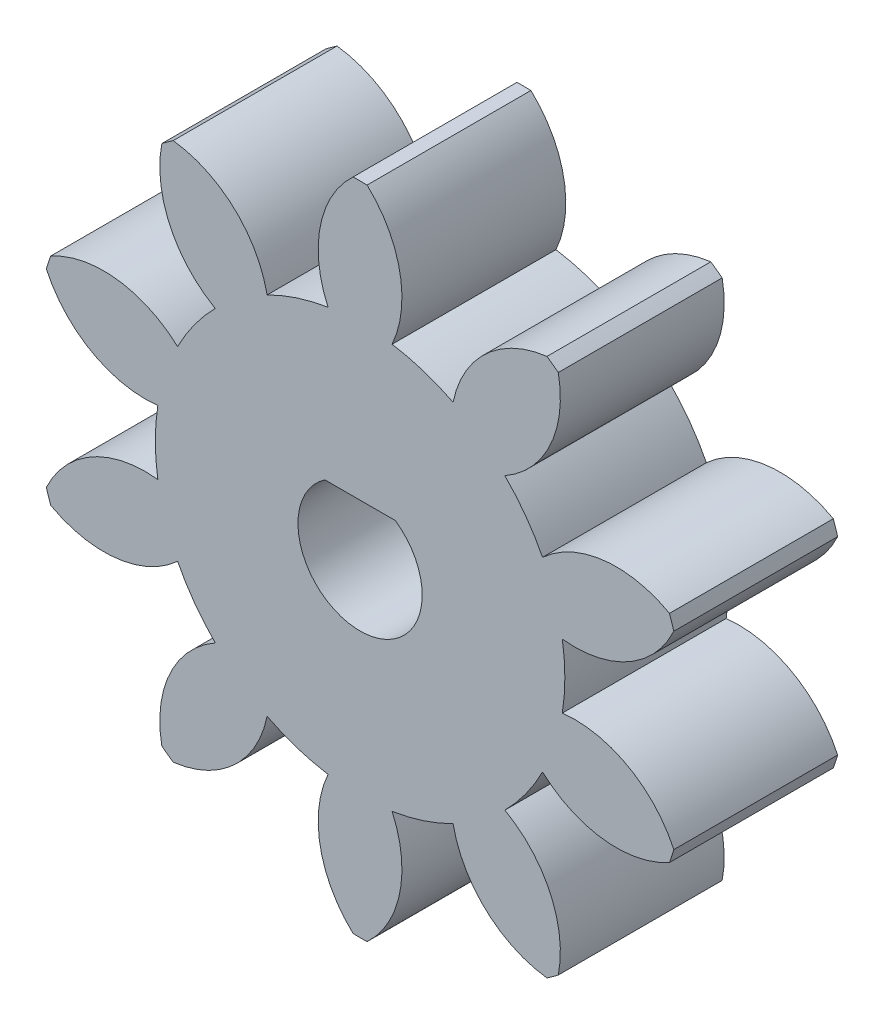
from build123d import *

# Parameters (mm, degrees)
SKETCH4_R           = 2
BOSS_EXTRUDE3_DEPTH = 6
SKETCH6_R           = 3.276903459
BOSS_EXTRUDE4_DEPTH = 6
CUT_EXTRUDE1_DEPTH  = 10


with BuildPart() as part:
    # Sketch4 → Boss-Extrude3 (new body)
    with BuildSketch(Plane.XY):
        with BuildLine():
            ThreePointArc((11.330682707, 3.9516616), (8.917819898, 4.428819506), (6.681915604, 3.403968986))
            ThreePointArc((6.681915604, 3.403968986), (6.066818441, 4.407801607), (5.302192362, 5.302995112))
            ThreePointArc((5.302192362, 5.302995112), (6.967815552, 7.112770233), (7.259627029, 9.554989032))
            ThreePointArc((7.259627029, 9.554989032), (7.053423028, 9.708203932), (6.843986457, 9.856969584))
            ThreePointArc((6.843986457, 9.856969584), (4.61147306, 8.824753264), (3.40498051, 6.681400208))
            ThreePointArc((3.40498051, 6.681400208), (2.317318441, 7.131972816), (1.172541409, 7.406763642))
            ThreePointArc((1.172541409, 7.406763642), (1.456299749, 9.849931218), (0.256880001, 11.997250213))
            ThreePointArc((0.256880001, 11.997250213), (0, 12), (-0.256880001, 11.997250213))
            ThreePointArc((-0.256880001, 11.997250213), (-1.456299749, 9.849931218), (-1.172541409, 7.406763642))
            ThreePointArc((-1.172541409, 7.406763642), (-2.317318441, 7.131972816), (-3.404980509, 6.681400207))
            ThreePointArc((-3.404980509, 6.681400207), (-4.61147306, 8.824753264), (-6.843986457, 9.856969584))
            ThreePointArc((-6.843986457, 9.856969584), (-7.053423028, 9.708203933), (-7.259627029, 9.554989032))
            ThreePointArc((-7.259627029, 9.554989032), (-6.967815552, 7.112770233), (-5.302192362, 5.302995112))
            ThreePointArc((-5.302192362, 5.302995112), (-6.066818441, 4.407801607), (-6.681915604, 3.403968986))
            ThreePointArc((-6.681915604, 3.403968986), (-8.917819898, 4.428819506), (-11.330682707, 3.9516616))
            ThreePointArc((-11.330682707, 3.9516616), (-11.412678196, 3.708203933), (-11.489443278, 3.463046803))
            ThreePointArc((-11.489443278, 3.463046803), (-9.817862641, 1.658772773), (-7.406586048, 1.173662691))
            ThreePointArc((-7.406586048, 1.173662691), (-7.499, 0), (-7.406586048, -1.173662691))
            ThreePointArc((-7.406586048, -1.173662691), (-9.817862641, -1.658772773), (-11.489443278, -3.463046803))
            ThreePointArc((-11.489443278, -3.463046803), (-11.412678196, -3.708203933), (-11.330682707, -3.9516616))
            ThreePointArc((-11.330682707, -3.9516616), (-8.917819898, -4.428819506), (-6.681915604, -3.403968986))
            ThreePointArc((-6.681915604, -3.403968986), (-6.066818441, -4.407801607), (-5.302192362, -5.302995112))
            ThreePointArc((-5.302192362, -5.302995112), (-6.967815552, -7.112770233), (-7.259627029, -9.554989032))
            ThreePointArc((-7.259627029, -9.554989032), (-7.053423028, -9.708203932), (-6.843986457, -9.856969584))
            ThreePointArc((-6.843986457, -9.856969584), (-4.61147306, -8.824753264), (-3.404980509, -6.681400207))
            ThreePointArc((-3.404980509, -6.681400207), (-2.317318441, -7.131972816), (-1.172541409, -7.406763642))
            ThreePointArc((-1.172541409, -7.406763642), (-1.456299749, -9.849931218), (-0.256880001, -11.997250213))
            ThreePointArc((-0.256880001, -11.997250213), (0, -12), (0.256880001, -11.997250213))
            ThreePointArc((0.256880001, -11.997250213), (1.456299749, -9.849931218), (1.172541409, -7.406763642))
            ThreePointArc((1.172541409, -7.406763642), (2.317318441, -7.131972816), (3.404980509, -6.681400207))
            ThreePointArc((3.404980509, -6.681400207), (4.61147306, -8.824753264), (6.843986457, -9.856969584))
            ThreePointArc((6.843986457, -9.856969584), (7.053423027, -9.708203933), (7.259627029, -9.554989032))
            ThreePointArc((7.259627029, -9.554989032), (6.967815552, -7.112770233), (5.302192362, -5.302995112))
            ThreePointArc((5.302192362, -5.302995112), (6.066818441, -4.407801607), (6.681915604, -3.403968986))
            ThreePointArc((6.681915604, -3.403968986), (8.917819898, -4.428819506), (11.330682707, -3.9516616))
            ThreePointArc((11.330682707, -3.9516616), (11.412678196, -3.708203932), (11.489443278, -3.463046803))
            ThreePointArc((11.489443278, -3.463046803), (9.817862641, -1.658772773), (7.406586048, -1.173662691))
            ThreePointArc((7.406586048, -1.173662691), (7.499, 0), (7.406586048, 1.173662691))
            ThreePointArc((7.406586048, 1.173662691), (9.817862641, 1.658772773), (11.489443278, 3.463046803))
            ThreePointArc((11.489443278, 3.463046803), (11.412678196, 3.708203932), (11.330682707, 3.9516616))
        make_face()
        Circle(SKETCH4_R, mode=Mode.SUBTRACT)
    extrude(amount=BOSS_EXTRUDE3_DEPTH)

    # Sketch6 → Boss-Extrude4 (add)
    with BuildSketch(Plane.XY.offset(6)):
        Circle(SKETCH6_R)
    extrude(amount=-BOSS_EXTRUDE4_DEPTH)

    # Sketch7 → Cut-Extrude1 (cut)
    with BuildSketch(Plane.XY.offset(6)):
        with BuildLine():
            Line((-1.288409873, 1.875), (1.288409873, 1.875))
            ThreePointArc((1.288409873, 1.875), (0, -2.275), (-1.288409873, 1.875))
        make_face()
    extrude(amount=-CUT_EXTRUDE1_DEPTH, mode=Mode.SUBTRACT)


solid = part.part
